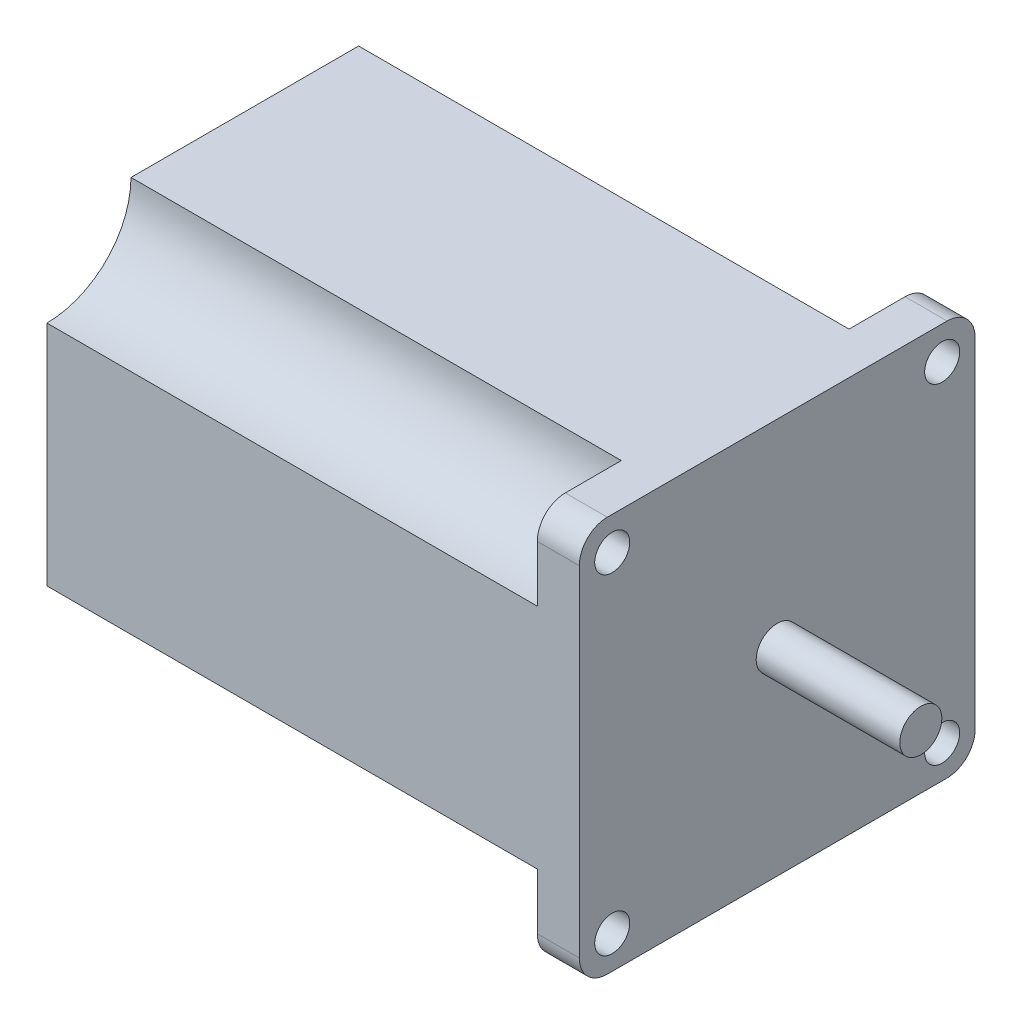
from build123d import *

# Parameters (mm, degrees)
SKETCH1_R           = 2.5
BOSS_EXTRUDE1_DEPTH = 76
SKETCH2_W           = 20.5
SKETCH2_H           = 3
CUT_EXTRUDE1_DEPTH  = 70


with BuildPart() as part:
    # Sketch1 → Boss-Extrude1 (new body)
    with BuildSketch(Plane(origin=(0, 0, 0), x_dir=(0, 0, -1), z_dir=(1, 0, 0))):
        with BuildLine():
            Line((-24.25, -28.25), (24.25, -28.25))
            ThreePointArc((24.25, -28.25), (27.078427125, -27.078427125), (28.25, -24.25))
            Line((28.25, -24.25), (28.25, 24.25))
            ThreePointArc((28.25, 24.25), (27.078427125, 27.078427125), (24.25, 28.25))
            Line((24.25, 28.25), (-24.25, 28.25))
            ThreePointArc((-24.25, 28.25), (-27.078427125, 27.078427125), (-28.25, 24.25))
            Line((-28.25, 24.25), (-28.25, -24.25))
            ThreePointArc((-28.25, -24.25), (-27.078427125, -27.078427125), (-24.25, -28.25))
        make_face()
        with Locations((-23.55, 23.55)):
            Circle(SKETCH1_R, mode=Mode.SUBTRACT)
        with Locations((-23.55, -23.55)):
            Circle(SKETCH1_R, mode=Mode.SUBTRACT)
        with Locations((23.55, -23.55)):
            Circle(SKETCH1_R, mode=Mode.SUBTRACT)
        with Locations((23.55, 23.55)):
            Circle(SKETCH1_R, mode=Mode.SUBTRACT)
    extrude(amount=-BOSS_EXTRUDE1_DEPTH)

    # Sketch2 → Revolve1 (revolve)
    with BuildSketch(Plane(origin=(0, 0, 0), x_dir=(1, 0, 0), z_dir=(0, 1, 0))):
        with Locations((10.25, 1.5)):
            Rectangle(SKETCH2_W, SKETCH2_H)
    revolve(axis=Axis((0, 0, 0), (1, 0, 0)))

    # Sketch3 → Cut-Extrude1 (cut)
    with BuildSketch(Plane.ZY.offset(76)):
        with BuildLine():
            Line((-28.25, -16.25), (-28.25, -24.25))
            ThreePointArc((-28.25, -24.25), (-27.078427125, -27.078427125), (-24.25, -28.25))
            Line((-24.25, -28.25), (-16.25, -28.25))
            ThreePointArc((-16.25, -28.25), (-19.764718626, -19.764718626), (-28.25, -16.25))
        make_face()
        with BuildLine():
            Line((-16.25, 28.25), (-24.25, 28.25))
            ThreePointArc((-24.25, 28.25), (-27.078427125, 27.078427125), (-28.25, 24.25))
            Line((-28.25, 24.25), (-28.25, 16.25))
            ThreePointArc((-28.25, 16.25), (-19.764718626, 19.764718626), (-16.25, 28.25))
        make_face()
        with BuildLine():
            Line((28.25, 16.25), (28.25, 24.25))
            ThreePointArc((28.25, 24.25), (27.078427125, 27.078427125), (24.25, 28.25))
            Line((24.25, 28.25), (16.25, 28.25))
            ThreePointArc((16.25, 28.25), (19.764718626, 19.764718626), (28.25, 16.25))
        make_face()
        with BuildLine():
            Line((16.25, -28.25), (24.25, -28.25))
            ThreePointArc((24.25, -28.25), (27.078427125, -27.078427125), (28.25, -24.25))
            Line((28.25, -24.25), (28.25, -16.25))
            ThreePointArc((28.25, -16.25), (19.764718626, -19.764718626), (16.25, -28.25))
        make_face()
    extrude(amount=-CUT_EXTRUDE1_DEPTH, mode=Mode.SUBTRACT)


solid = part.part
